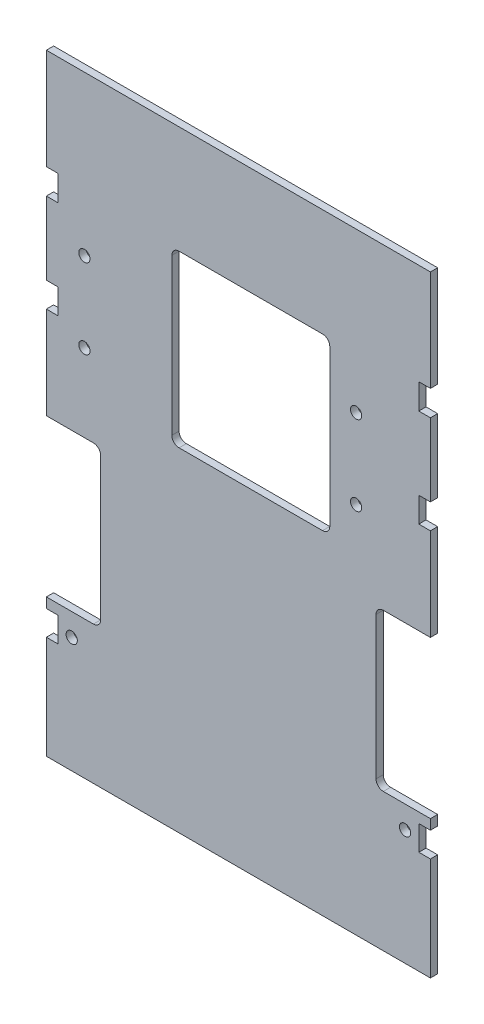
from build123d import *

# Parameters (mm, degrees)
SKETCH_1_R      = 1.55
EXTRUDE_1_DEPTH = 2


with BuildPart() as part:
    # 草图1 → 凸台-拉伸1 (new body)
    with BuildSketch(Plane.XY):
        with BuildLine():
            Line((-53, 72.523086953), (-53, 52.405955819))
            Line((-53, 52.405955819), (-49.8, 52.405955819))
            Line((-49.8, 52.405955819), (-49.8, 45.507725731))
            Line((-49.8, 45.507725731), (-53, 45.507725731))
            Line((-53, 45.507725731), (-53, 20.011565656))
            Line((-53, 20.011565656), (-40, 20.011565656))
            ThreePointArc((-40, 20.011565656), (-38.585786438, 19.425779218), (-38, 18.011565656))
            Line((-38, 18.011565656), (-38, -21.289037005))
            ThreePointArc((-38, -21.289037005), (-38.585786438, -22.703250568), (-40, -23.289037005))
            Line((-40, -23.289037005), (-53, -23.289037005))
            Line((-53, -23.289037005), (-53, -26.067193504))
            Line((-53, -26.067193504), (-49.8, -26.067193504))
            Line((-49.8, -26.067193504), (-49.8, -32.930143701))
            Line((-49.8, -32.930143701), (-53, -32.930143701))
            Line((-53, -32.930143701), (-53, -61.384473154))
            Line((-53, -61.384473154), (53, -61.384473154))
            Line((53, -61.384473154), (53, -32.930143701))
            Line((53, -32.930143701), (49.8, -32.930143701))
            Line((49.8, -32.930143701), (49.8, -26.067193504))
            Line((49.8, -26.067193504), (53, -26.067193504))
            Line((53, -26.067193504), (53, -23.289037005))
            Line((53, -23.289037005), (40, -23.289037005))
            ThreePointArc((40, -23.289037005), (38.585786438, -22.703250568), (38, -21.289037005))
            Line((38, -21.289037005), (38, 18.011565656))
            ThreePointArc((38, 18.011565656), (38.585786438, 19.425779218), (40, 20.011565656))
            Line((40, 20.011565656), (53, 20.011565656))
            Line((53, 20.011565656), (53, 45.507725731))
            Line((53, 45.507725731), (49.8, 45.507725731))
            Line((49.8, 45.507725731), (49.8, 52.405955819))
            Line((49.8, 52.405955819), (53, 52.405955819))
            Line((53, 52.405955819), (53, 67.484473154))
            Line((53, 67.484473154), (53, 72.523086953))
            Line((53, 72.523086953), (49.8, 72.523086953))
            Line((49.8, 72.523086953), (49.8, 79.540910094))
            Line((49.8, 79.540910094), (53, 79.540910094))
            Line((53, 79.540910094), (53, 107.384473154))
            Line((53, 107.384473154), (-53, 107.384473154))
            Line((-53, 107.384473154), (-53, 79.540910094))
            Line((-53, 79.540910094), (-49.8, 79.540910094))
            Line((-49.8, 79.540910094), (-49.8, 72.523086953))
            Line((-49.8, 72.523086953), (-53, 72.523086953))
        make_face()
        with Locations((-42.5, 63.5)):
            Circle(SKETCH_1_R, mode=Mode.SUBTRACT)
        with Locations((32.5, 63.515526846)):
            Circle(SKETCH_1_R, mode=Mode.SUBTRACT)
        with Locations((-42.5, 41.5)):
            Circle(SKETCH_1_R, mode=Mode.SUBTRACT)
        with Locations((32.5, 41.515526846)):
            Circle(SKETCH_1_R, mode=Mode.SUBTRACT)
        with Locations((-46, -29.484473154)):
            Circle(SKETCH_1_R, mode=Mode.SUBTRACT)
        with Locations((46, -29.484473154)):
            Circle(SKETCH_1_R, mode=Mode.SUBTRACT)
        with BuildLine():
            Line((-16.369193533, 77.65782048), (23.228994882, 77.65782048))
            ThreePointArc((23.228994882, 77.65782048), (24.643208444, 77.072034042), (25.228994882, 75.65782048))
            Line((25.228994882, 75.65782048), (25.228994882, 32.660489145))
            ThreePointArc((25.228994882, 32.660489145), (24.643208444, 31.246275583), (23.228994882, 30.660489145))
            Line((23.228994882, 30.660489145), (-16.369193533, 30.660489145))
            ThreePointArc((-16.369193533, 30.660489145), (-17.783407096, 31.246275583), (-18.369193533, 32.660489145))
            Line((-18.369193533, 32.660489145), (-18.369193533, 75.65782048))
            ThreePointArc((-18.369193533, 75.65782048), (-17.783407096, 77.072034042), (-16.369193533, 77.65782048))
        make_face(mode=Mode.SUBTRACT)
    extrude(amount=EXTRUDE_1_DEPTH)


solid = part.part
